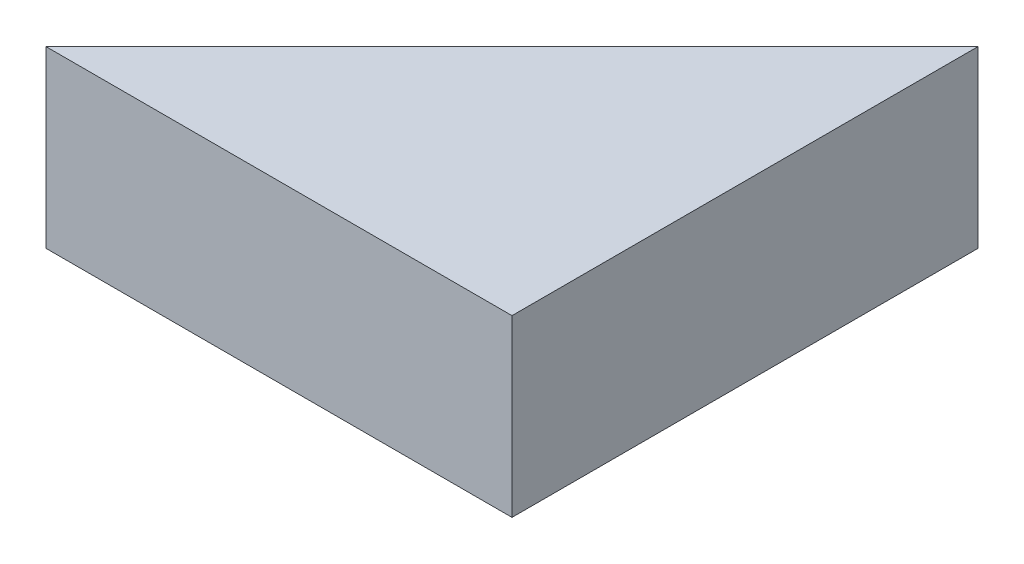
from build123d import *

# Parameters (mm, degrees)
BOSS_EXTRUDE1_DEPTH = 30


with BuildPart() as part:
    # Sketch1 → Boss-Extrude1 (new body)
    with BuildSketch(Plane(origin=(0, 0, 0), x_dir=(1, 0, 0), z_dir=(0, 1, 0))):
        Polygon((0, 0), (0, 80), (-80, 0), align=None)
    extrude(amount=BOSS_EXTRUDE1_DEPTH)


solid = part.part
